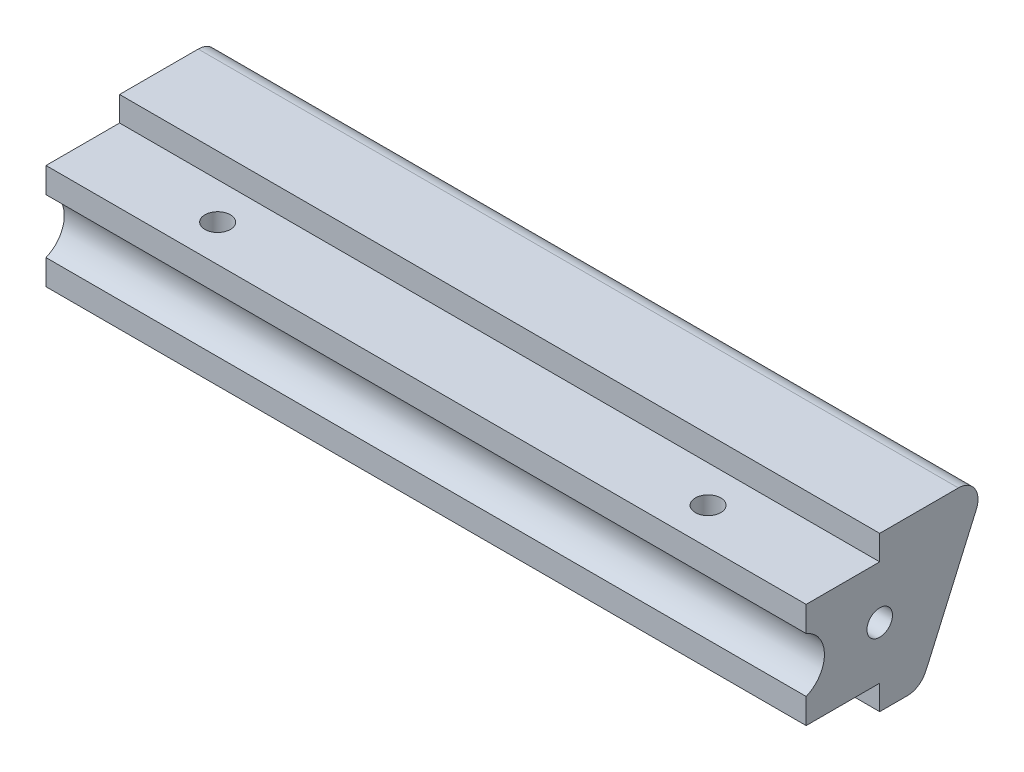
from build123d import *

# Parameters (mm, degrees)
BOSS_EXTRUDE1_DEPTH = 98.425
CUT_EXTRUDE2_DEPTH  = 98.425
SKETCH5_R           = 1.651
CUT_EXTRUDE3_DEPTH  = 13.5992
FILLET1_R           = 2.54
SKETCH6_R           = 1.651
CUT_EXTRUDE4_DEPTH  = 98.425


with BuildPart() as part:
    # Sketch1 → Boss-Extrude1 (new body)
    with BuildSketch(Plane(origin=(0, 0, 0), x_dir=(0, 0, -1), z_dir=(1, 0, 0))):
        with BuildLine():
            Line((0, 16.7996), (0, 3.2004))
            Line((0, 3.2004), (9.525, 3.2004))
            Line((9.525, 3.2004), (9.525, 0))
            Line((9.525, 0), (14.605, 0))
            ThreePointArc((14.605, 0), (15.279774052, 1.174548121), (15.868724182, 2.394392806))
            Line((15.868724182, 2.394392806), (23.603930172, 20))
            Line((23.603930172, 20), (9.525, 20))
            Line((9.525, 20), (9.525, 16.7996))
            Line((9.525, 16.7996), (0, 16.7996))
        make_face()
    extrude(amount=BOSS_EXTRUDE1_DEPTH)

    # Sketch4 → Cut-Extrude2 (cut)
    with BuildSketch(Plane.ZY):
        with BuildLine():
            Line((0, 13.526281186), (0, 6.473718814))
            ThreePointArc((0, 6.473718814), (-2.36728, 10), (0, 13.526281186))
        make_face()
    extrude(amount=-CUT_EXTRUDE2_DEPTH, mode=Mode.SUBTRACT)

    # Sketch5 → Cut-Extrude3 (cut)
    with BuildSketch(Plane(origin=(0, 16.7996, 0), x_dir=(1, 0, 0), z_dir=(0, 1, 0))):
        with Locations((17.4625, 4.7625)):
            Circle(SKETCH5_R)
        with Locations((80.9625, 4.7625)):
            Circle(SKETCH5_R)
    extrude(amount=-CUT_EXTRUDE3_DEPTH, mode=Mode.SUBTRACT)

    # Fillet1
    fillet1_edges = [part.edges().sort_by_distance(p)[0] for p in [
        (49.2125, 20, -23.603930172),
        (49.2125, 0, -14.605),
    ]]
    fillet(fillet1_edges, radius=FILLET1_R)

    # Sketch6 → Cut-Extrude4 (cut)
    with BuildSketch(Plane(origin=(98.425, 0, 0), x_dir=(0, 0, -1), z_dir=(1, 0, 0))):
        with Locations((9.525, 10)):
            Circle(SKETCH6_R)
    extrude(amount=-CUT_EXTRUDE4_DEPTH, mode=Mode.SUBTRACT)


solid = part.part
